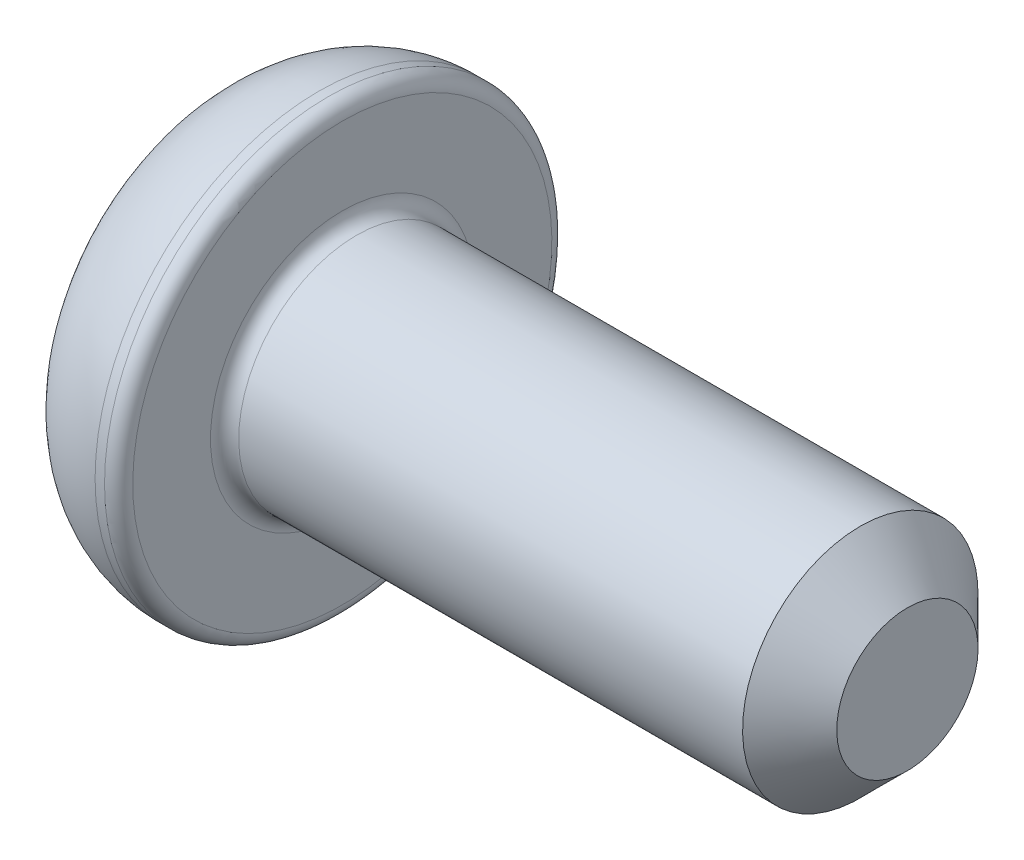
from build123d import *

# Parameters (mm, degrees)
CUT_EXTRUDE_1_DEPTH = 1.5
FILLET_1_R          = 0.3
CHAMFER_1_SIZE      = 1


with BuildPart() as part:
    # Эскиз1 → Повернуть1 (revolve)
    with BuildSketch(Plane.XY):
        with BuildLine():
            Line((0, 0), (0, 3.625))
            ThreePointArc((0, 3.625), (0.908821487, 4.451033224), (2.1, 4.75))
            Line((2.1, 4.75), (2.6, 4.75))
            Line((2.6, 4.75), (2.6, 2.5))
            Line((2.6, 2.5), (14.6, 2.5))
            Line((14.6, 2.5), (14.6, 0))
            Line((14.6, 0), (0, 0))
        make_face()
    revolve(axis=Axis((14.6, 0, 0), (-1, 0, 0)))

    # Эскиз2 → Вырез-Вытянуть1 (cut)
    with BuildSketch(Plane.ZY):
        Polygon((0.866025404, 1.5), (-0.866025404, 1.5), (-1.732050808, 0), (-0.866025404, -1.5), (0.866025404, -1.5), (1.732050808, 0), align=None)
    extrude(amount=-CUT_EXTRUDE_1_DEPTH, mode=Mode.SUBTRACT)

    # Скругление1
    fillet_1_edges = [part.edges().sort_by_distance(p)[0] for p in [
        (2.6, -2.5, 0),
        (2.6, -4.75, 0),
    ]]
    fillet(fillet_1_edges, radius=FILLET_1_R)

    # Фаска1
    chamfer_1_edges = [part.edges().sort_by_distance(p)[0] for p in [
        (14.6, -2.5, 0),
    ]]
    chamfer(chamfer_1_edges, length=CHAMFER_1_SIZE)


solid = part.part
